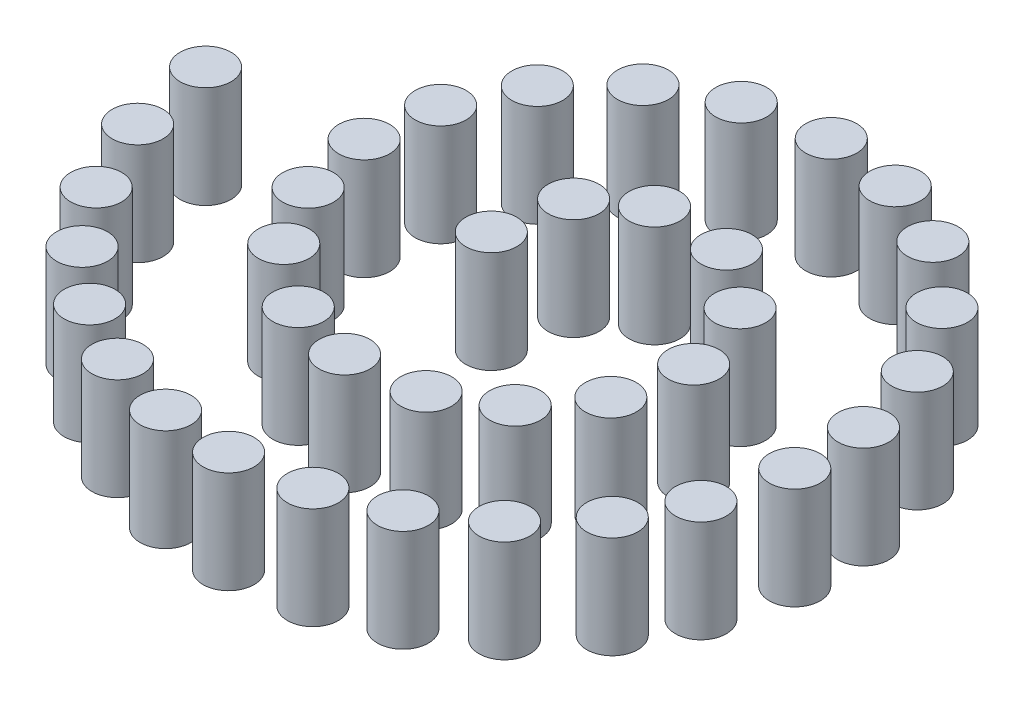
from build123d import *

# Parameters (mm, degrees)
SKETCH_3_R         = 25
EXTRUDE_1_DEPTH    = 100
EXTRUDE_1_2_DEPTH  = 100
EXTRUDE_1_3_DEPTH  = 100
EXTRUDE_1_4_DEPTH  = 100
EXTRUDE_1_5_DEPTH  = 100
EXTRUDE_1_6_DEPTH  = 100
EXTRUDE_1_7_DEPTH  = 100
EXTRUDE_1_8_DEPTH  = 100
EXTRUDE_1_9_DEPTH  = 100
EXTRUDE_1_10_DEPTH = 100
EXTRUDE_1_11_DEPTH = 100
EXTRUDE_1_12_DEPTH = 100
EXTRUDE_1_13_DEPTH = 100
EXTRUDE_1_14_DEPTH = 100
EXTRUDE_1_15_DEPTH = 100
EXTRUDE_1_16_DEPTH = 100
EXTRUDE_1_17_DEPTH = 100
EXTRUDE_1_18_DEPTH = 100
EXTRUDE_1_19_DEPTH = 100
EXTRUDE_1_20_DEPTH = 100
EXTRUDE_1_21_DEPTH = 100
EXTRUDE_1_22_DEPTH = 100
EXTRUDE_1_23_DEPTH = 100
EXTRUDE_1_24_DEPTH = 100
EXTRUDE_1_25_DEPTH = 100
EXTRUDE_1_26_DEPTH = 100
EXTRUDE_1_27_DEPTH = 100
EXTRUDE_1_28_DEPTH = 100
EXTRUDE_1_29_DEPTH = 100
EXTRUDE_1_30_DEPTH = 100
EXTRUDE_1_31_DEPTH = 100
EXTRUDE_1_32_DEPTH = 100
EXTRUDE_1_33_DEPTH = 100
EXTRUDE_1_34_DEPTH = 100
EXTRUDE_1_35_DEPTH = 100
EXTRUDE_1_36_DEPTH = 100
EXTRUDE_1_37_DEPTH = 100
EXTRUDE_1_38_DEPTH = 100


with BuildPart() as part:
    # 草圖3 → 填料-伸長1 (new body)
    with BuildSketch(Plane(origin=(0, 0, 0), x_dir=(1, 0, 0), z_dir=(0, 1, 0))):
        with Locations((-350, 0)):
            Circle(SKETCH_3_R)
    extrude(amount=EXTRUDE_1_DEPTH)


with BuildPart() as body_2:
    # 草圖3 → Extrude 1 2 (new body)
    with BuildSketch(Plane(origin=(0, 0, 0), x_dir=(1, 0, 0), z_dir=(0, 1, 0))):
        with Locations((-70, 0)):
            Circle(SKETCH_3_R)
    extrude(amount=EXTRUDE_1_2_DEPTH)


with BuildPart() as body_3:
    # 草圖3 → Extrude 1 3 (new body)
    with BuildSketch(Plane(origin=(0, 0, 0), x_dir=(1, 0, 0), z_dir=(0, 1, 0))):
        with Locations((-57.650301132, 68.301691178)):
            Circle(SKETCH_3_R)
    extrude(amount=EXTRUDE_1_3_DEPTH)


with BuildPart() as body_4:
    # 草圖3 → Extrude 1 4 (new body)
    with BuildSketch(Plane(origin=(0, 0, 0), x_dir=(1, 0, 0), z_dir=(0, 1, 0))):
        with Locations((-11.841092291, 101.730855571)):
            Circle(SKETCH_3_R)
    extrude(amount=EXTRUDE_1_4_DEPTH)


with BuildPart() as body_5:
    # 草圖3 → Extrude 1 5 (new body)
    with BuildSketch(Plane(origin=(0, 0, 0), x_dir=(1, 0, 0), z_dir=(0, 1, 0))):
        with Locations((59.965849817, 100.45403563)):
            Circle(SKETCH_3_R)
    extrude(amount=EXTRUDE_1_5_DEPTH)


with BuildPart() as body_6:
    # 草圖3 → Extrude 1 6 (new body)
    with BuildSketch(Plane(origin=(0, 0, 0), x_dir=(1, 0, 0), z_dir=(0, 1, 0))):
        with Locations((116.456918875, 57.335343342)):
            Circle(SKETCH_3_R)
    extrude(amount=EXTRUDE_1_6_DEPTH)


with BuildPart() as body_7:
    # 草圖3 → Extrude 1 7 (new body)
    with BuildSketch(Plane(origin=(0, 0, 0), x_dir=(1, 0, 0), z_dir=(0, 1, 0))):
        with Locations((141.456918875, -13.181960557)):
            Circle(SKETCH_3_R)
    extrude(amount=EXTRUDE_1_7_DEPTH)


with BuildPart() as body_8:
    # 草圖3 → Extrude 1 8 (new body)
    with BuildSketch(Plane(origin=(0, 0, 0), x_dir=(1, 0, 0), z_dir=(0, 1, 0))):
        with Locations((128.848902731, -81.756922074)):
            Circle(SKETCH_3_R)
    extrude(amount=EXTRUDE_1_8_DEPTH)


with BuildPart() as body_9:
    # 草圖3 → Extrude 1 9 (new body)
    with BuildSketch(Plane(origin=(0, 0, 0), x_dir=(1, 0, 0), z_dir=(0, 1, 0))):
        with Locations((88.893813144, -135.508302325)):
            Circle(SKETCH_3_R)
    extrude(amount=EXTRUDE_1_9_DEPTH)


with BuildPart() as body_10:
    # 草圖3 → Extrude 1 10 (new body)
    with BuildSketch(Plane(origin=(0, 0, 0), x_dir=(1, 0, 0), z_dir=(0, 1, 0))):
        with Locations((33.418343703, -167.302093337)):
            Circle(SKETCH_3_R)
    extrude(amount=EXTRUDE_1_10_DEPTH)


with BuildPart() as body_11:
    # 草圖3 → Extrude 1 11 (new body)
    with BuildSketch(Plane(origin=(0, 0, 0), x_dir=(1, 0, 0), z_dir=(0, 1, 0))):
        with Locations((-38.16269755, -175.668894072)):
            Circle(SKETCH_3_R)
    extrude(amount=EXTRUDE_1_11_DEPTH)


with BuildPart() as body_12:
    # 草圖3 → Extrude 1 12 (new body)
    with BuildSketch(Plane(origin=(0, 0, 0), x_dir=(1, 0, 0), z_dir=(0, 1, 0))):
        with Locations((-101.078169097, -158.127451001)):
            Circle(SKETCH_3_R)
    extrude(amount=EXTRUDE_1_12_DEPTH)


with BuildPart() as body_13:
    # 草圖3 → Extrude 1 13 (new body)
    with BuildSketch(Plane(origin=(0, 0, 0), x_dir=(1, 0, 0), z_dir=(0, 1, 0))):
        with Locations((-161.744684376, -111.650259863)):
            Circle(SKETCH_3_R)
    extrude(amount=EXTRUDE_1_13_DEPTH)


with BuildPart() as body_14:
    # 草圖3 → Extrude 1 14 (new body)
    with BuildSketch(Plane(origin=(0, 0, 0), x_dir=(1, 0, 0), z_dir=(0, 1, 0))):
        with Locations((-197.551384439, -51.955212723)):
            Circle(SKETCH_3_R)
    extrude(amount=EXTRUDE_1_14_DEPTH)


with BuildPart() as body_15:
    # 草圖3 → Extrude 1 15 (new body)
    with BuildSketch(Plane(origin=(0, 0, 0), x_dir=(1, 0, 0), z_dir=(0, 1, 0))):
        with Locations((-211.092819556, 16.476996416)):
            Circle(SKETCH_3_R)
    extrude(amount=EXTRUDE_1_15_DEPTH)


with BuildPart() as body_16:
    # 草圖3 → Extrude 1 16 (new body)
    with BuildSketch(Plane(origin=(0, 0, 0), x_dir=(1, 0, 0), z_dir=(0, 1, 0))):
        with Locations((-202.389783895, 82.73221897)):
            Circle(SKETCH_3_R)
    extrude(amount=EXTRUDE_1_16_DEPTH)


with BuildPart() as body_17:
    # 草圖3 → Extrude 1 17 (new body)
    with BuildSketch(Plane(origin=(0, 0, 0), x_dir=(1, 0, 0), z_dir=(0, 1, 0))):
        with Locations((-171.619971932, 146.671255538)):
            Circle(SKETCH_3_R)
    extrude(amount=EXTRUDE_1_17_DEPTH)


with BuildPart() as body_18:
    # 草圖3 → Extrude 1 18 (new body)
    with BuildSketch(Plane(origin=(0, 0, 0), x_dir=(1, 0, 0), z_dir=(0, 1, 0))):
        with Locations((-120.60105859, 199.207694957)):
            Circle(SKETCH_3_R)
    extrude(amount=EXTRUDE_1_18_DEPTH)


with BuildPart() as body_19:
    # 草圖3 → Extrude 1 19 (new body)
    with BuildSketch(Plane(origin=(0, 0, 0), x_dir=(1, 0, 0), z_dir=(0, 1, 0))):
        with Locations((-57.650301132, 232.545323192)):
            Circle(SKETCH_3_R)
    extrude(amount=EXTRUDE_1_19_DEPTH)


with BuildPart() as body_20:
    # 草圖3 → Extrude 1 20 (new body)
    with BuildSketch(Plane(origin=(0, 0, 0), x_dir=(1, 0, 0), z_dir=(0, 1, 0))):
        with Locations((17.159601471, 245.954116702)):
            Circle(SKETCH_3_R)
    extrude(amount=EXTRUDE_1_20_DEPTH)


with BuildPart() as body_21:
    # 草圖3 → Extrude 1 21 (new body)
    with BuildSketch(Plane(origin=(0, 0, 0), x_dir=(1, 0, 0), z_dir=(0, 1, 0))):
        with Locations((88.893813144, 236.868486463)):
            Circle(SKETCH_3_R)
    extrude(amount=EXTRUDE_1_21_DEPTH)


with BuildPart() as body_22:
    # 草圖3 → Extrude 1 22 (new body)
    with BuildSketch(Plane(origin=(0, 0, 0), x_dir=(1, 0, 0), z_dir=(0, 1, 0))):
        with Locations((154.455028368, 208.18257955)):
            Circle(SKETCH_3_R)
    extrude(amount=EXTRUDE_1_22_DEPTH)


with BuildPart() as body_23:
    # 草圖3 → Extrude 1 23 (new body)
    with BuildSketch(Plane(origin=(0, 0, 0), x_dir=(1, 0, 0), z_dir=(0, 1, 0))):
        with Locations((215.082233843, 156.485467264)):
            Circle(SKETCH_3_R)
    extrude(amount=EXTRUDE_1_23_DEPTH)


with BuildPart() as body_24:
    # 草圖3 → Extrude 1 24 (new body)
    with BuildSketch(Plane(origin=(0, 0, 0), x_dir=(1, 0, 0), z_dir=(0, 1, 0))):
        with Locations((257.044071733, 90.369489462)):
            Circle(SKETCH_3_R)
    extrude(amount=EXTRUDE_1_24_DEPTH)


with BuildPart() as body_25:
    # 草圖3 → Extrude 1 25 (new body)
    with BuildSketch(Plane(origin=(0, 0, 0), x_dir=(1, 0, 0), z_dir=(0, 1, 0))):
        with Locations((278.194241876, 16.476996416)):
            Circle(SKETCH_3_R)
    extrude(amount=EXTRUDE_1_25_DEPTH)


with BuildPart() as body_26:
    # 草圖3 → Extrude 1 26 (new body)
    with BuildSketch(Plane(origin=(0, 0, 0), x_dir=(1, 0, 0), z_dir=(0, 1, 0))):
        with Locations((279.306747869, -51.955212723)):
            Circle(SKETCH_3_R)
    extrude(amount=EXTRUDE_1_26_DEPTH)


with BuildPart() as body_27:
    # 草圖3 → Extrude 1 27 (new body)
    with BuildSketch(Plane(origin=(0, 0, 0), x_dir=(1, 0, 0), z_dir=(0, 1, 0))):
        with Locations((261.25529287, -125.891865261)):
            Circle(SKETCH_3_R)
    extrude(amount=EXTRUDE_1_27_DEPTH)


with BuildPart() as body_28:
    # 草圖3 → Extrude 1 28 (new body)
    with BuildSketch(Plane(origin=(0, 0, 0), x_dir=(1, 0, 0), z_dir=(0, 1, 0))):
        with Locations((231.369014083, -182.854149818)):
            Circle(SKETCH_3_R)
    extrude(amount=EXTRUDE_1_28_DEPTH)


with BuildPart() as body_29:
    # 草圖3 → Extrude 1 29 (new body)
    with BuildSketch(Plane(origin=(0, 0, 0), x_dir=(1, 0, 0), z_dir=(0, 1, 0))):
        with Locations((182.005402855, -239.115641422)):
            Circle(SKETCH_3_R)
    extrude(amount=EXTRUDE_1_29_DEPTH)


with BuildPart() as body_30:
    # 草圖3 → Extrude 1 30 (new body)
    with BuildSketch(Plane(origin=(0, 0, 0), x_dir=(1, 0, 0), z_dir=(0, 1, 0))):
        with Locations((123.219646887, -279.829798551)):
            Circle(SKETCH_3_R)
    extrude(amount=EXTRUDE_1_30_DEPTH)


with BuildPart() as body_31:
    # 草圖3 → Extrude 1 31 (new body)
    with BuildSketch(Plane(origin=(0, 0, 0), x_dir=(1, 0, 0), z_dir=(0, 1, 0))):
        with Locations((59.965849817, -304.829798551)):
            Circle(SKETCH_3_R)
    extrude(amount=EXTRUDE_1_31_DEPTH)


with BuildPart() as body_32:
    # 草圖3 → Extrude 1 32 (new body)
    with BuildSketch(Plane(origin=(0, 0, 0), x_dir=(1, 0, 0), z_dir=(0, 1, 0))):
        with Locations((-11.841092291, -315.613449212)):
            Circle(SKETCH_3_R)
    extrude(amount=EXTRUDE_1_32_DEPTH)


with BuildPart() as body_33:
    # 草圖3 → Extrude 1 33 (new body)
    with BuildSketch(Plane(origin=(0, 0, 0), x_dir=(1, 0, 0), z_dir=(0, 1, 0))):
        with Locations((-78.491005827, -310.753098595)):
            Circle(SKETCH_3_R)
    extrude(amount=EXTRUDE_1_33_DEPTH)


with BuildPart() as body_34:
    # 草圖3 → Extrude 1 34 (new body)
    with BuildSketch(Plane(origin=(0, 0, 0), x_dir=(1, 0, 0), z_dir=(0, 1, 0))):
        with Locations((-145.307158175, -291.0619161)):
            Circle(SKETCH_3_R)
    extrude(amount=EXTRUDE_1_34_DEPTH)


with BuildPart() as body_35:
    # 草圖3 → Extrude 1 35 (new body)
    with BuildSketch(Plane(origin=(0, 0, 0), x_dir=(1, 0, 0), z_dir=(0, 1, 0))):
        with Locations((-205.58458455, -258.11999609)):
            Circle(SKETCH_3_R)
    extrude(amount=EXTRUDE_1_35_DEPTH)


with BuildPart() as body_36:
    # 草圖3 → Extrude 1 36 (new body)
    with BuildSketch(Plane(origin=(0, 0, 0), x_dir=(1, 0, 0), z_dir=(0, 1, 0))):
        with Locations((-258.156456586, -212.919225251)):
            Circle(SKETCH_3_R)
    extrude(amount=EXTRUDE_1_36_DEPTH)


with BuildPart() as body_37:
    # 草圖3 → Extrude 1 37 (new body)
    with BuildSketch(Plane(origin=(0, 0, 0), x_dir=(1, 0, 0), z_dir=(0, 1, 0))):
        with Locations((-301.608879536, -155.613127806)):
            Circle(SKETCH_3_R)
    extrude(amount=EXTRUDE_1_37_DEPTH)


with BuildPart() as body_38:
    # 草圖3 → Extrude 1 38 (new body)
    with BuildSketch(Plane(origin=(0, 0, 0), x_dir=(1, 0, 0), z_dir=(0, 1, 0))):
        with Locations((-334.826589347, -81.756922074)):
            Circle(SKETCH_3_R)
    extrude(amount=EXTRUDE_1_38_DEPTH)


solid = Compound([part.part, body_2.part, body_3.part, body_4.part, body_5.part, body_6.part, body_7.part, body_8.part, body_9.part, body_10.part, body_11.part, body_12.part, body_13.part, body_14.part, body_15.part, body_16.part, body_17.part, body_18.part, body_19.part, body_20.part, body_21.part, body_22.part, body_23.part, body_24.part, body_25.part, body_26.part, body_27.part, body_28.part, body_29.part, body_30.part, body_31.part, body_32.part, body_33.part, body_34.part, body_35.part, body_36.part, body_37.part, body_38.part])
